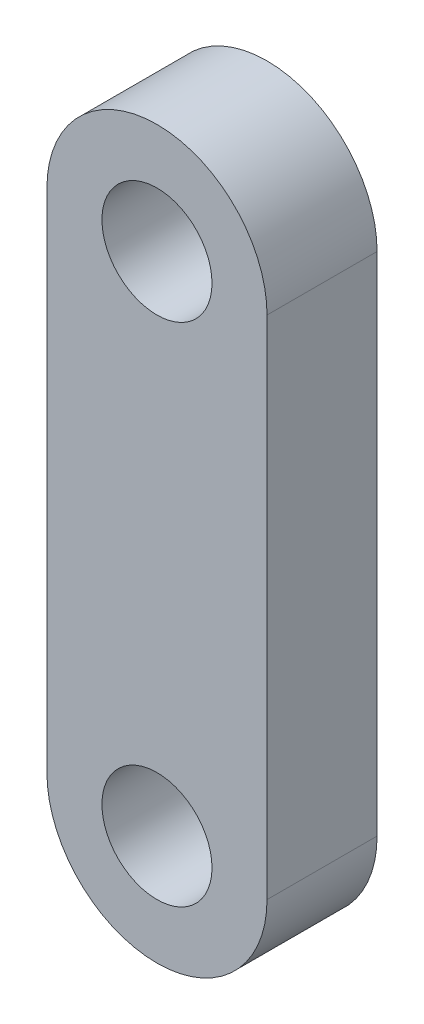
from build123d import *

# Parameters (mm, degrees)
SKETCH_1_R      = 2.5
EXTRUDE_1_DEPTH = 2.5


with BuildPart() as part:
    # 草圖1 → 填料-伸長1 (new, symmetric)
    with BuildSketch(Plane.XY):
        with BuildLine():
            Line((5, 0), (5, 23))
            ThreePointArc((5, 23), (0, 28), (-5, 23))
            Line((-5, 23), (-5, 0))
            ThreePointArc((-5, 0), (0, -5), (5, 0))
        make_face()
        Circle(SKETCH_1_R, mode=Mode.SUBTRACT)
        with Locations((0, 23)):
            Circle(SKETCH_1_R, mode=Mode.SUBTRACT)
    extrude(amount=EXTRUDE_1_DEPTH, both=True)


solid = part.part
